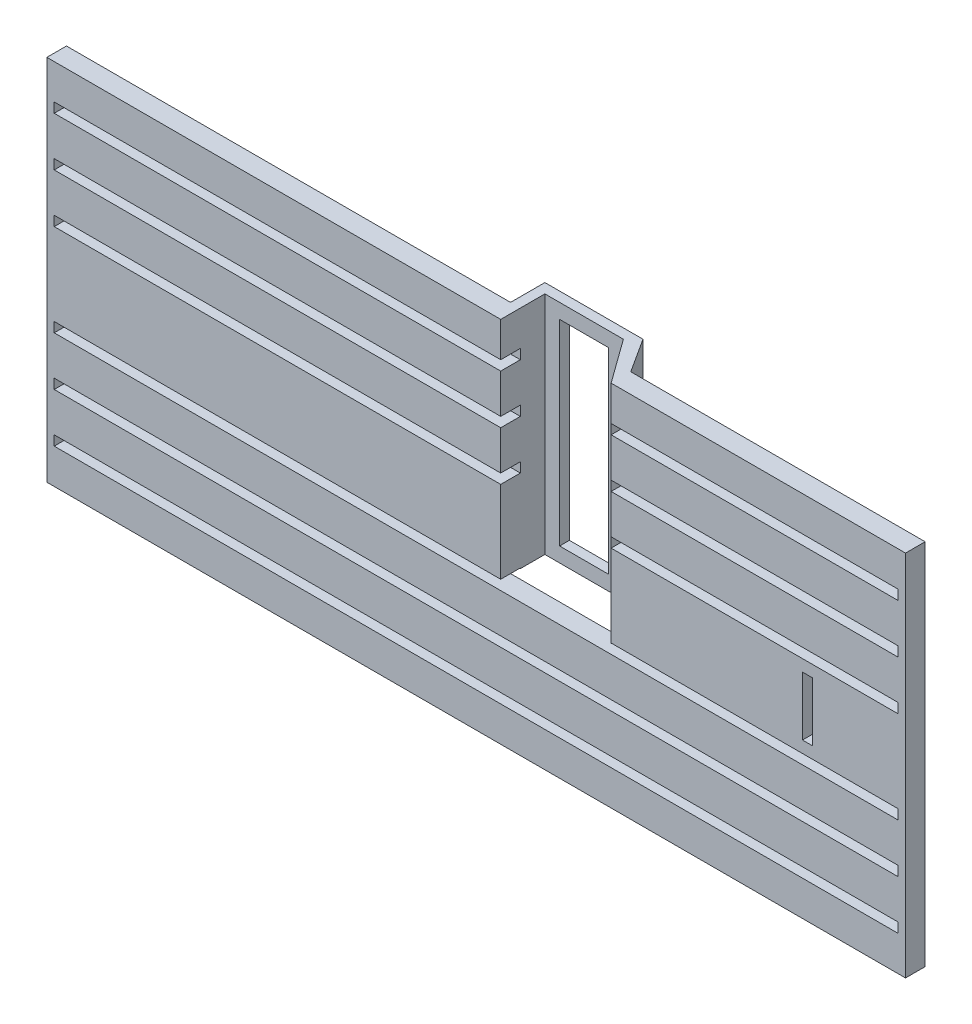
from build123d import *

# Parameters (mm, degrees)
SKETCH1_W           = 222.25
SKETCH1_H           = 95.25
BOSS_EXTRUDE1_DEPTH = 5.08
SKETCH2_W           = 218.44
SKETCH2_H           = 2.54
CUT_EXTRUDE1_DEPTH  = 5.08
SKETCH5_W           = 2.54
SKETCH5_H           = 15.24
CUT_EXTRUDE4_DEPTH  = 5.08
SKETCH7_W           = 28.575
SKETCH7_H           = 21.74875
CUT_EXTRUDE5_DEPTH  = 5.08
SKETCH8_W           = 28.575
SKETCH8_H           = 21.2725
CUT_EXTRUDE6_DEPTH  = 5.08
SKETCH11_W          = 28.575
SKETCH11_H          = 10.16
CUT_EXTRUDE8_DEPTH  = 5.08
BOSS_EXTRUDE2_DEPTH = 58.42
SKETCH12_W          = 12.7
SKETCH12_H          = 50.8
CUT_EXTRUDE9_DEPTH  = 2.54


with BuildPart() as part:
    # Sketch1 → Boss-Extrude1 (new body)
    with BuildSketch(Plane.XY):
        Rectangle(SKETCH1_W, SKETCH1_H)
    extrude(amount=BOSS_EXTRUDE1_DEPTH)

    # Sketch2 → Cut-Extrude1 (cut)
    with BuildSketch(Plane(origin=(0, 0, 0), x_dir=(-1, 0, 0), z_dir=(0, 0, -1))):
        with Locations((0, 24.60625)):
            Rectangle(SKETCH2_W, SKETCH2_H)
        with Locations((0, 11.90625)):
            Rectangle(SKETCH2_W, SKETCH2_H)
        with Locations((0, 37.30625)):
            Rectangle(SKETCH2_W, SKETCH2_H)
        with Locations((0, -11.90625)):
            Rectangle(SKETCH2_W, SKETCH2_H)
        with Locations((0, -24.60625)):
            Rectangle(SKETCH2_W, SKETCH2_H)
        with Locations((0, -37.30625)):
            Rectangle(SKETCH2_W, SKETCH2_H)
    extrude(amount=-CUT_EXTRUDE1_DEPTH, mode=Mode.SUBTRACT)

    # Sketch5 → Cut-Extrude4 (cut)
    with BuildSketch(Plane(origin=(0, 0, 0), x_dir=(-1, 0, 0), z_dir=(0, 0, -1))):
        with Locations((-85.725, 0)):
            Rectangle(SKETCH5_W, SKETCH5_H)
    extrude(amount=-CUT_EXTRUDE4_DEPTH, mode=Mode.SUBTRACT)

    # Sketch7 → Cut-Extrude5 (cut)
    with BuildSketch(Plane(origin=(0, 0, 0), x_dir=(-1, 0, 0), z_dir=(0, 0, -1))):
        with Locations((-20.6375, 36.750625)):
            Rectangle(SKETCH7_W, SKETCH7_H)
    extrude(amount=-CUT_EXTRUDE5_DEPTH, mode=Mode.SUBTRACT)

    # Sketch8 → Cut-Extrude6 (cut)
    with BuildSketch(Plane(origin=(0, 0, 0), x_dir=(-1, 0, 0), z_dir=(0, 0, -1))):
        with Locations((-20.6375, 0)):
            Rectangle(SKETCH8_W, SKETCH8_H)
    extrude(amount=-CUT_EXTRUDE6_DEPTH, mode=Mode.SUBTRACT)

    # Sketch11 → Cut-Extrude8 (cut)
    with BuildSketch(Plane(origin=(0, 0, 0), x_dir=(-1, 0, 0), z_dir=(0, 0, -1))):
        with Locations((-20.6375, 18.25625)):
            Rectangle(SKETCH11_W, SKETCH11_H)
    extrude(amount=-CUT_EXTRUDE8_DEPTH, mode=Mode.SUBTRACT)

    # Sketch10 → Boss-Extrude2 (add)
    with BuildSketch(Plane(origin=(0, 47.625, 0), x_dir=(1, 0, 0), z_dir=(0, 1, 0))):
        Polygon((6.35, 0), (6.35, 6.35), (26.67, 6.35), (34.925, -5.08), (34.925, 0), (29.21, 8.89), (3.81, 8.89), (3.81, 0), align=None)
    extrude(amount=-BOSS_EXTRUDE2_DEPTH)

    # Sketch12 → Cut-Extrude9 (cut)
    with BuildSketch(Plane.XY.offset(-6.35)):
        with Locations((16.51, 18.415)):
            Rectangle(SKETCH12_W, SKETCH12_H)
    extrude(amount=-CUT_EXTRUDE9_DEPTH, mode=Mode.SUBTRACT)


solid = part.part
